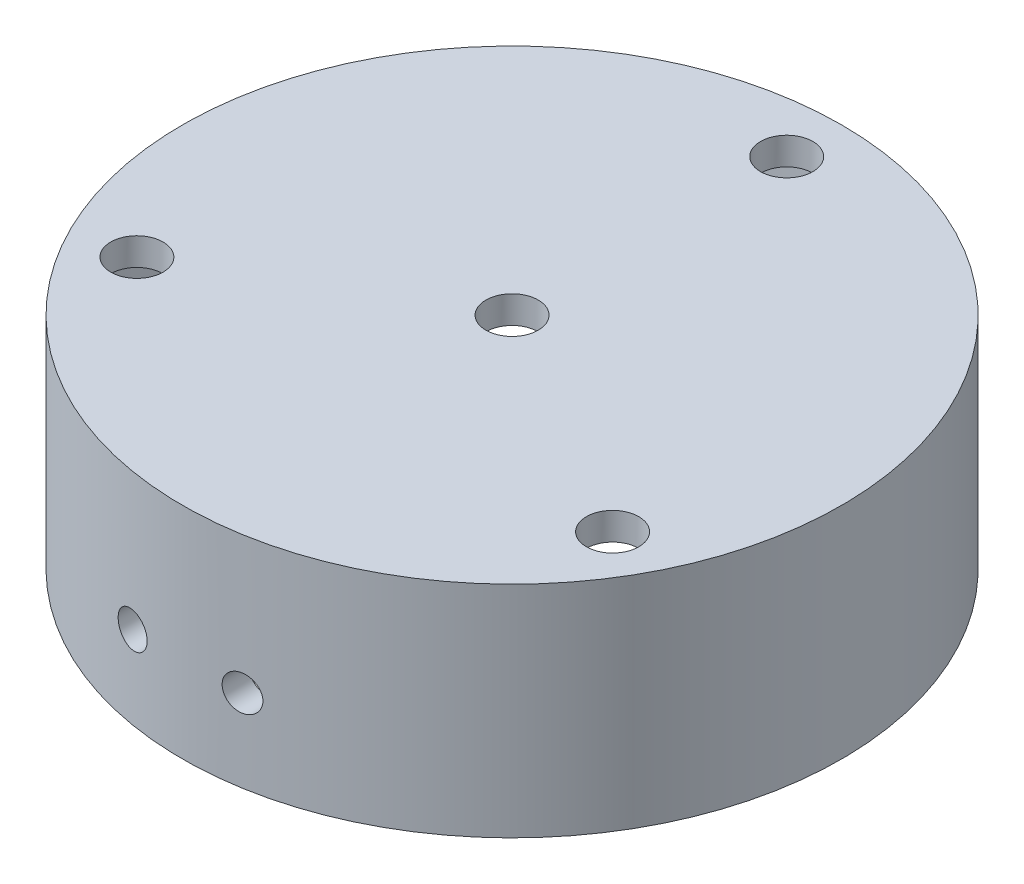
from build123d import *

# Parameters (mm, degrees)
CROQUIS2_R                 = 4.7625
CORTAR_EXTRUIR1_DEPTH      = 41
CROQUIS3_R                 = 3.175
CORTAR_EXTRUIR2_DEPTH      = 61
CORTAR_EXTRUIR2_DEPTH_BACK = 61
CROQUIS4_R                 = 4.7625
CORTAR_EXTRUIR4_DEPTH      = 1.0000001
CORTAR_EXTRUIR4_DEPTH_BACK = 41.0000001


with BuildPart() as part:
    # Croquis1 → Revolución1 (revolve)
    with BuildSketch(Plane.XY):
        Polygon((0, 40), (60, 40), (60, 0), (55, 0), (55, 35), (0, 35), align=None)
    revolve(axis=Axis((0, 0, 0), (0, 1, 0)))

    # Croquis2 → Cortar-Extruir1 (cut, through all)
    with BuildSketch(Plane(origin=(0, 40, 0), x_dir=(1, 0, 0), z_dir=(0, 1, 0))):
        Circle(CROQUIS2_R)
    extrude(amount=-CORTAR_EXTRUIR1_DEPTH, mode=Mode.SUBTRACT)

    # Croquis3 → Cortar-Extruir2 (cut, two sides)
    with BuildSketch(Plane.XY) as cortar_extruir2_sk:
        with Locations((-10, 15)):
            Circle(CROQUIS3_R)
        with Locations((10, 15)):
            Circle(CROQUIS3_R)
    extrude(amount=CORTAR_EXTRUIR2_DEPTH, mode=Mode.SUBTRACT)
    extrude(cortar_extruir2_sk.sketch, amount=-CORTAR_EXTRUIR2_DEPTH_BACK, mode=Mode.SUBTRACT)

    # Croquis4 → Cortar-Extruir4 (cut, two sides)
    with BuildSketch(Plane(origin=(0, 40, 0), x_dir=(1, 0, 0), z_dir=(0, 1, 0))) as cortar_extruir4_sk:
        with Locations((0, 50)):
            Circle(CROQUIS4_R)
        with Locations((43.301270189, -25)):
            Circle(CROQUIS4_R)
        with Locations((-43.301270189, -25)):
            Circle(CROQUIS4_R)
    extrude(amount=CORTAR_EXTRUIR4_DEPTH, mode=Mode.SUBTRACT)
    extrude(cortar_extruir4_sk.sketch, amount=-CORTAR_EXTRUIR4_DEPTH_BACK, mode=Mode.SUBTRACT)


solid = part.part
